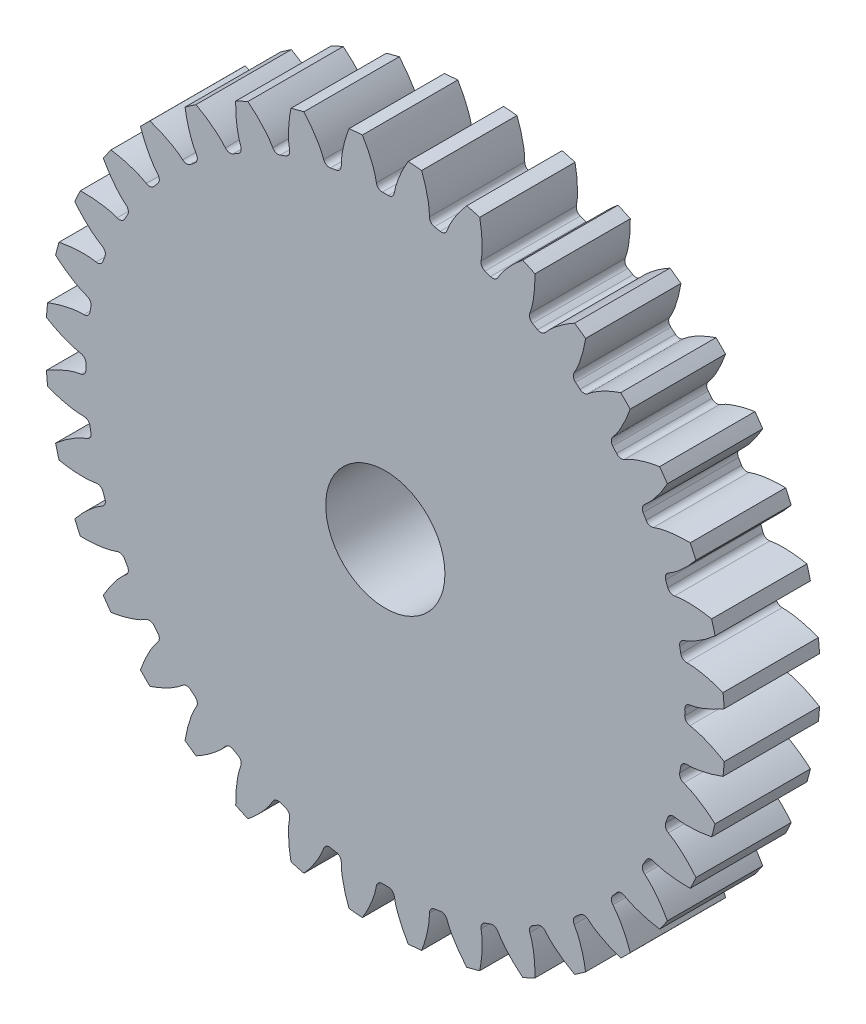
from build123d import *

# Parameters (mm, degrees)
SKETCH3_R                = 15.08125
BOSS_EXTRUDE1_DEPTH      = 2.116666667
BOSS_EXTRUDE1_DEPTH_BACK = 2.116666667
SKETCH5_W                = 11.1252
SKETCH5_H                = 2.645833333
CUT_EXTRUDE1_DEPTH       = 3.116666667
FILLET1_R                = 0.266307122
CIRPATTERN1_COUNT        = 36
FILLET1_OF_CIRPATTERN1_R = 0.266307122
SCALE1_SCALE             = 1.2


with BuildPart() as part:
    # Sketch3 → Boss-Extrude1 (new body, two sides)
    with BuildSketch(Plane.XY) as boss_extrude1_sk:
        Circle(SKETCH3_R)
    extrude(amount=BOSS_EXTRUDE1_DEPTH)
    extrude(boss_extrude1_sk.sketch, amount=-BOSS_EXTRUDE1_DEPTH_BACK)

    # Sketch5 → Cut-Revolve1 (revolve, cut)
    with BuildSketch(Plane(origin=(0, 0, 0), x_dir=(0, 0, -1), z_dir=(1, 0, 0))):
        with Locations((0, 1.322916667)):
            Rectangle(SKETCH5_W, SKETCH5_H)
    revolve(axis=Axis((0, 0, 5.5626), (0, 0, -1)), mode=Mode.SUBTRACT)

    # Sketch4 → Cut-Extrude1 (cut, symmetric)
    with BuildSketch(Plane.XY):
        with BuildLine():
            Line((13.289826256, 0.381906465), (13.420318207, 0.38565638))
            add(Edge.make_bspline(
                [(13.420318207, 0.38565638), (13.422914897, 0.38575914), (13.430195068, 0.386134439), (13.443946597, 0.387187852), (13.466365456, 0.389395164), (13.494898024, 0.392925562), (13.531733888, 0.398312963), (13.575066094, 0.405719519), (13.622616226, 0.414969571), (13.67426481, 0.426231474), (13.725711415, 0.438526192), (13.776951293, 0.451776589), (13.827917483, 0.465864991), (13.889556653, 0.48398078), (13.963328411, 0.507162879), (14.049336344, 0.53638473), (14.14660985, 0.572034133), (14.245435829, 0.611046633), (14.342416431, 0.65163616), (14.44007817, 0.695175469), (14.534340064, 0.739093632), (14.63189425, 0.787299214), (14.721762066, 0.833111555), (14.822031607, 0.88729925), (14.90283031, 0.931864642), (14.985934696, 0.980284581), (15.026328374, 1.004202572), (15.046949136, 1.016574283)],
                knots=[0, 0, 0, 0, 0, 0.005376749, 0.015083688, 0.02853182, 0.04661014, 0.064854849, 0.092110526, 0.119476176, 0.146842496, 0.174208854, 0.201574956, 0.228941013, 0.256307345, 0.307035032, 0.361767352, 0.416499661, 0.471231937, 0.525964282, 0.580696616, 0.635428982, 0.690161387, 0.744893688, 0.799626082, 0.854358407, 0.909090914, 0.909090914, 0.909090914, 0.909090914, 0.909090914], degree=4))
            ThreePointArc((15.046949136, 1.016574283), (15.08125, 0), (15.046949136, -1.016574283))
            add(Edge.make_bspline(
                [(13.420318207, -0.38565638), (13.422914897, -0.38575914), (13.430195068, -0.386134439), (13.443946597, -0.387187852), (13.466365456, -0.389395164), (13.494898024, -0.392925562), (13.531733888, -0.398312963), (13.575066094, -0.405719519), (13.622616226, -0.414969571), (13.67426481, -0.426231474), (13.725711415, -0.438526192), (13.776951293, -0.451776589), (13.827917483, -0.465864991), (13.889556653, -0.48398078), (13.963328411, -0.507162879), (14.049336344, -0.53638473), (14.14660985, -0.572034133), (14.245435829, -0.611046633), (14.342416431, -0.65163616), (14.44007817, -0.695175469), (14.534340064, -0.739093632), (14.63189425, -0.787299214), (14.721762066, -0.833111555), (14.822031607, -0.88729925), (14.90283031, -0.931864642), (14.985934696, -0.980284581), (15.026328374, -1.004202572), (15.046949136, -1.016574283)],
                knots=[0, 0, 0, 0, 0, 0.005376749, 0.015083688, 0.02853182, 0.04661014, 0.064854849, 0.092110526, 0.119476176, 0.146842496, 0.174208854, 0.201574956, 0.228941013, 0.256307345, 0.307035032, 0.361767352, 0.416499661, 0.471231937, 0.525964282, 0.580696616, 0.635428982, 0.690161387, 0.744893688, 0.799626082, 0.854358407, 0.909090914, 0.909090914, 0.909090914, 0.909090914, 0.909090914], degree=4))
            Line((13.420318207, -0.38565638), (13.289826256, -0.381906465))
            ThreePointArc((13.289826256, -0.381906465), (13.2953125, 0), (13.289826256, 0.381906465))
        make_face()
    cut_extrude1 = extrude(amount=CUT_EXTRUDE1_DEPTH, both=True, mode=Mode.SUBTRACT)

    # Fillet1
    fillet1_edges = [part.edges().sort_by_distance(p)[0] for p in [
        (13.289826256, -0.381906465, 0),
        (13.289826256, 0.381906465, 0),
    ]]
    fillet(fillet1_edges, radius=FILLET1_R)

    # CirPattern1: Cut-Extrude1 ×36 about axis
    cirpattern1_axis = Axis((0, 0, 5.5626), (0, 0, -1))
    for i in range(1, CIRPATTERN1_COUNT):
        add(cut_extrude1.rotate(cirpattern1_axis, i * 360 / CIRPATTERN1_COUNT), mode=Mode.SUBTRACT)

    # Fillet1 of CirPattern1
    fillet1_of_cirpattern1_edges = [part.edges().sort_by_distance(p)[0] for p in [
        (13.021606572, -2.683858559, 0),
        (13.154241295, -1.931649663, 0),
        (12.357731961, -4.904262968, 0),
        (12.618971369, -4.186513594, 0),
        (11.318373917, -6.975653829, 0),
        (11.700280382, -6.314172428, 0),
        (9.93511281, -8.835092978, 0),
        (10.426082298, -8.249978327, 0),
        (8.249978327, -10.426082298, 0),
        (8.835092978, -9.93511281, 0),
        (6.314172428, -11.700280382, 0),
        (6.975653829, -11.318373917, 0),
        (4.186513594, -12.618971369, 0),
        (4.904262968, -12.357731961, 0),
        (1.931649663, -13.154241295, 0),
        (2.683858559, -13.021606572, 0),
        (-0.381906465, -13.289826256, 0),
        (0.381906465, -13.289826256, 0),
        (-2.683858559, -13.021606572, 0),
        (-1.931649663, -13.154241295, 0),
        (-4.904262968, -12.357731961, 0),
        (-4.186513594, -12.618971369, 0),
        (-6.975653829, -11.318373917, 0),
        (-6.314172428, -11.700280382, 0),
        (-8.835092978, -9.93511281, 0),
        (-8.249978327, -10.426082298, 0),
        (-10.426082298, -8.249978327, 0),
        (-9.93511281, -8.835092978, 0),
        (-11.700280382, -6.314172428, 0),
        (-11.318373917, -6.975653829, 0),
        (-12.618971369, -4.186513594, 0),
        (-12.357731961, -4.904262968, 0),
        (-13.154241295, -1.931649663, 0),
        (-13.021606572, -2.683858559, 0),
        (-13.289826256, 0.381906465, 0),
        (-13.289826256, -0.381906465, 0),
        (-13.021606572, 2.683858559, 0),
        (-13.154241295, 1.931649663, 0),
        (-12.357731961, 4.904262968, 0),
        (-12.618971369, 4.186513594, 0),
        (-11.318373917, 6.975653829, 0),
        (-11.700280382, 6.314172428, 0),
        (-9.93511281, 8.835092978, 0),
        (-10.426082298, 8.249978327, 0),
        (-8.249978327, 10.426082298, 0),
        (-8.835092978, 9.93511281, 0),
        (-6.314172428, 11.700280382, 0),
        (-6.975653829, 11.318373917, 0),
        (-4.186513594, 12.618971369, 0),
        (-4.904262968, 12.357731961, 0),
        (-1.931649663, 13.154241295, 0),
        (-2.683858559, 13.021606572, 0),
        (0.381906465, 13.289826256, 0),
        (-0.381906465, 13.289826256, 0),
        (2.683858559, 13.021606572, 0),
        (1.931649663, 13.154241295, 0),
        (4.904262968, 12.357731961, 0),
        (4.186513594, 12.618971369, 0),
        (6.975653829, 11.318373917, 0),
        (6.314172428, 11.700280382, 0),
        (8.835092978, 9.93511281, 0),
        (8.249978327, 10.426082298, 0),
        (10.426082298, 8.249978327, 0),
        (9.93511281, 8.835092978, 0),
        (11.700280382, 6.314172428, 0),
        (11.318373917, 6.975653829, 0),
        (12.618971369, 4.186513594, 0),
        (12.357731961, 4.904262968, 0),
        (13.154241295, 1.931649663, 0),
        (13.021606572, 2.683858559, 0),
    ]]
    fillet(fillet1_of_cirpattern1_edges, radius=FILLET1_OF_CIRPATTERN1_R)


with BuildPart() as part_1:
    # Scale1: scaled about (0, -1.3e-08, 0)
    add(part.part.scale(SCALE1_SCALE).moved(Location((0, 3e-09, 0))))


solid = part_1.part
